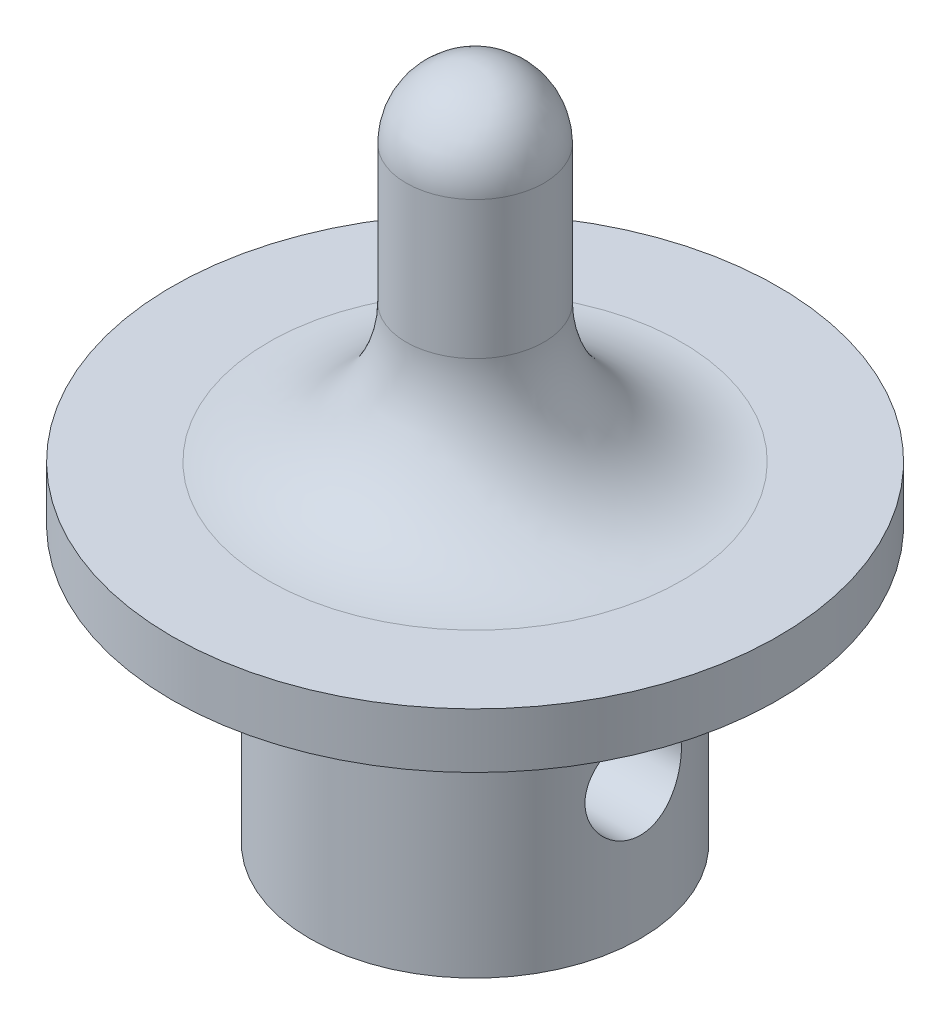
from build123d import *

# Parameters (mm, degrees)
SKETCH1_R               = 6
BOSS_EXTRUDE1_DEPTH     = 10
SKETCH2_R               = 11
BOSS_EXTRUDE2_DEPTH     = 2
FILLET1_R               = 5
SKETCH5_R               = 1.75
CUT_EXTRUDE1_DEPTH      = 12
CUT_EXTRUDE1_DEPTH_BACK = 12


with BuildPart() as part:
    # Sketch1 → Boss-Extrude1 (new body)
    with BuildSketch(Plane(origin=(0, 0, 0), x_dir=(1, 0, 0), z_dir=(0, 1, 0))):
        Circle(SKETCH1_R)
    extrude(amount=BOSS_EXTRUDE1_DEPTH)

    # Sketch2 → Boss-Extrude2 (add)
    with BuildSketch(Plane(origin=(0, 10, 0), x_dir=(1, 0, 0), z_dir=(0, 1, 0))):
        Circle(SKETCH2_R)
    extrude(amount=BOSS_EXTRUDE2_DEPTH)

    # Sketch3 → Revolve1 (revolve)
    with BuildSketch(Plane(origin=(0, 0, 0), x_dir=(0, 0, -1), z_dir=(1, 0, 0))):
        with BuildLine():
            Line((0, 12), (-2.5, 12))
            Line((-2.5, 12), (-2.5, 22))
            ThreePointArc((-2.5, 22), (-1.767766953, 23.767766953), (0, 24.5))
            Line((0, 24.5), (0, 12))
        make_face()
    revolve(axis=Axis((0, 24.5, 0), (0, -1, 0)))

    # Fillet1
    fillet1_edges = [part.edges().sort_by_distance(p)[0] for p in [
        (0, 12, -2.5),
    ]]
    fillet(fillet1_edges, radius=FILLET1_R)

    # Sketch5 → Cut-Extrude1 (cut, two sides)
    with BuildSketch(Plane(origin=(0, 0, 0), x_dir=(0, 0, -1), z_dir=(1, 0, 0))) as cut_extrude1_sk:
        with Locations((0, 5)):
            Circle(SKETCH5_R)
    extrude(amount=CUT_EXTRUDE1_DEPTH, mode=Mode.SUBTRACT)
    extrude(cut_extrude1_sk.sketch, amount=-CUT_EXTRUDE1_DEPTH_BACK, mode=Mode.SUBTRACT)


solid = part.part
